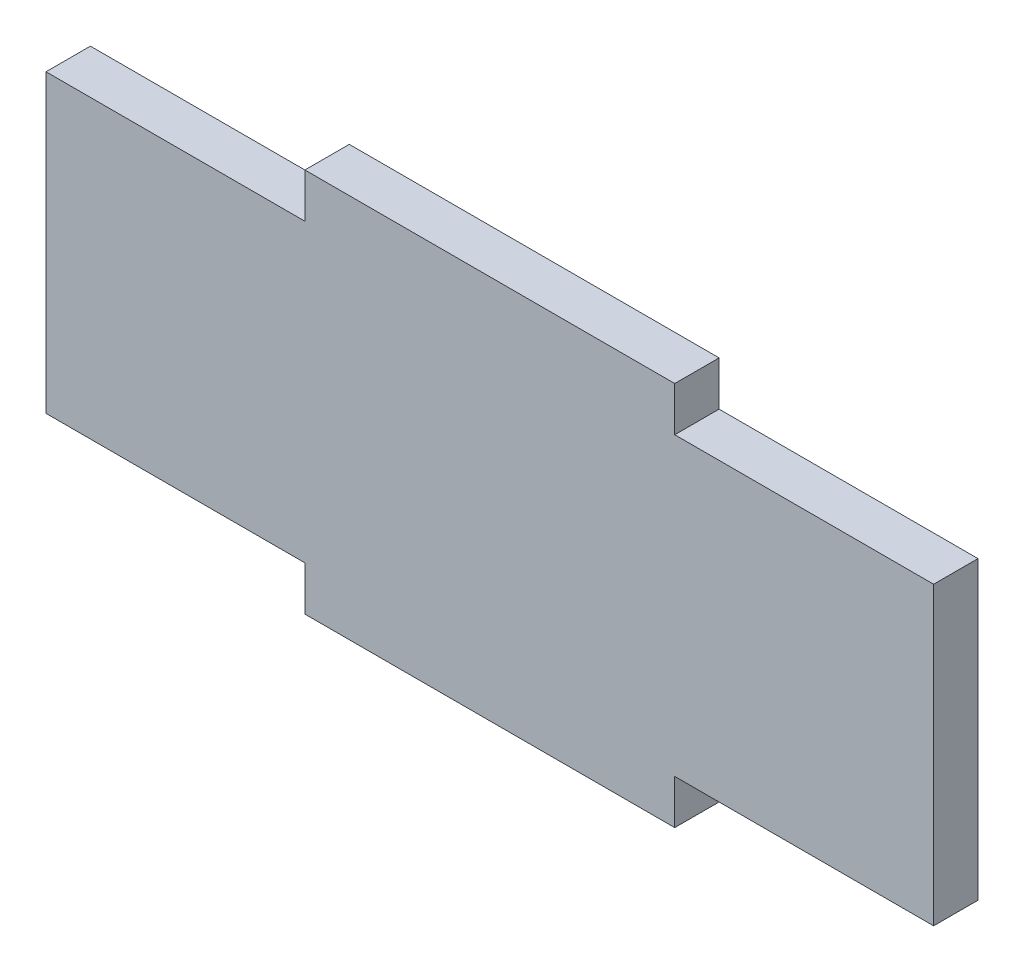
from build123d import *

# Parameters (mm, degrees)
ESQUISSE1_W        = 120
ESQUISSE1_H        = 40
BOSS_EXTRU_1_DEPTH = 6
ESQUISSE2_W        = 50
ESQUISSE2_H        = 6
BOSS_EXTRU_2_DEPTH = 6


with BuildPart() as part:
    # Esquisse1 → Boss.-Extru.1 (new body)
    with BuildSketch(Plane.XY):
        Rectangle(ESQUISSE1_W, ESQUISSE1_H)
    extrude(amount=BOSS_EXTRU_1_DEPTH)

    # Esquisse2 → Boss.-Extru.2 (add)
    with BuildSketch(Plane.XY.offset(6)):
        with Locations((0, 23)):
            Rectangle(ESQUISSE2_W, ESQUISSE2_H)
        with Locations((0, -23)):
            Rectangle(ESQUISSE2_W, ESQUISSE2_H)
    extrude(amount=-BOSS_EXTRU_2_DEPTH)


solid = part.part
